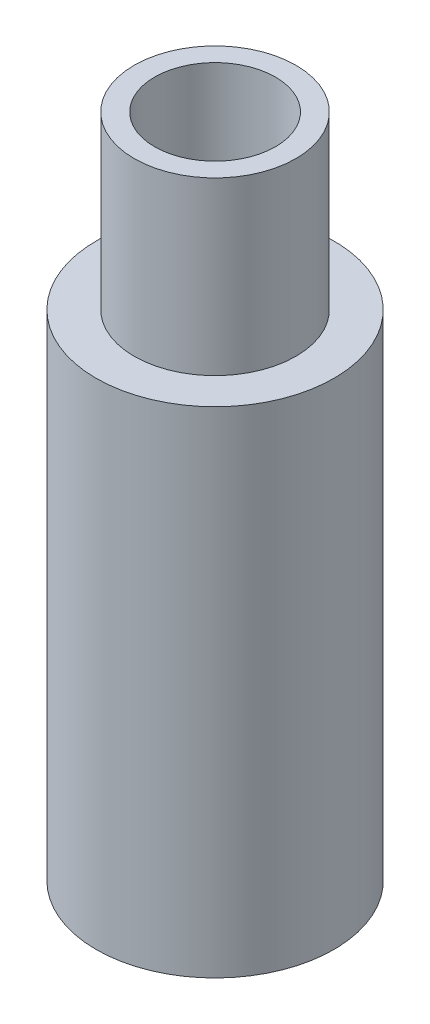
from build123d import *

# Parameters (mm, degrees)
SKETCH1_R           = 6.25
SKETCH1_R_2         = 3.175
BOSS_EXTRUDE1_DEPTH = 35
SKETCH2_OUTSIDE_W   = 22.342
SKETCH2_OUTSIDE_H   = 22.342
SKETCH2_OUTSIDE_R   = 4.25
CUT_EXTRUDE1_DEPTH  = 9
SKETCH3_R           = 4.25
CUT_EXTRUDE2_DEPTH  = 9


with BuildPart() as part:
    # Sketch1 → Boss-Extrude1 (new body)
    with BuildSketch(Plane(origin=(0, 0, 0), x_dir=(1, 0, 0), z_dir=(0, 1, 0))):
        Circle(SKETCH1_R)
        Circle(SKETCH1_R_2, mode=Mode.SUBTRACT)
    extrude(amount=BOSS_EXTRUDE1_DEPTH)

    # Sketch2 outside → Cut-Extrude1 (cut)
    with BuildSketch(Plane(origin=(0, 35, 0), x_dir=(1, 0, 0), z_dir=(0, 1, 0))):
        Rectangle(SKETCH2_OUTSIDE_W, SKETCH2_OUTSIDE_H)
        Circle(SKETCH2_OUTSIDE_R, mode=Mode.SUBTRACT)
    extrude(amount=-CUT_EXTRUDE1_DEPTH, mode=Mode.SUBTRACT)

    # Sketch3 → Cut-Extrude2 (cut)
    with BuildSketch(Plane.XZ):
        Circle(SKETCH3_R)
    extrude(amount=-CUT_EXTRUDE2_DEPTH, mode=Mode.SUBTRACT)


solid = part.part
